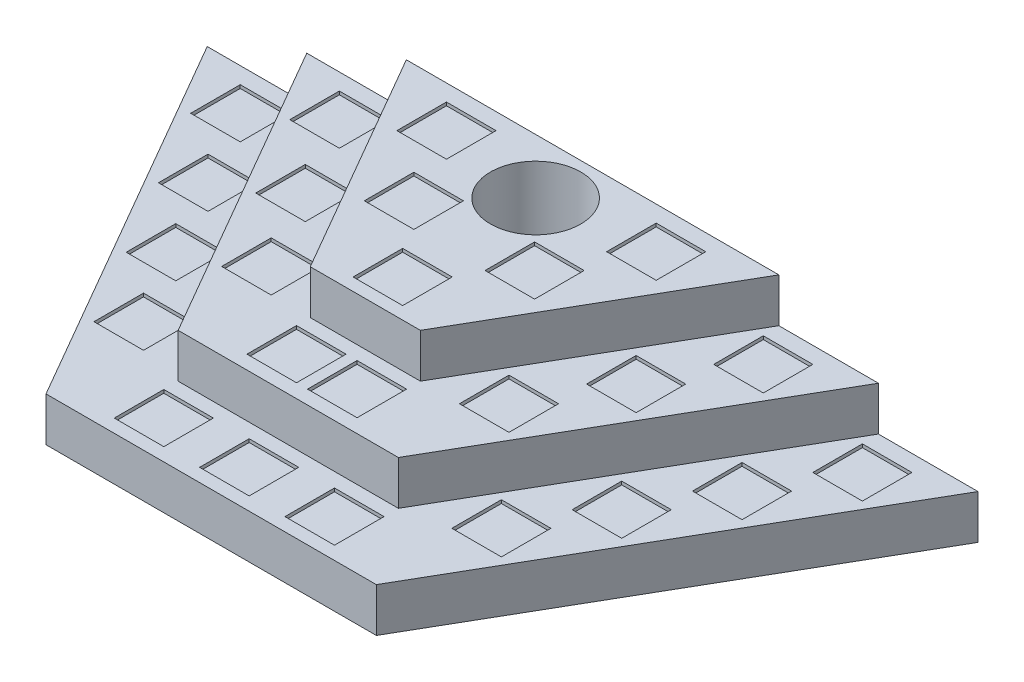
from build123d import *

# Parameters (mm, degrees)
BOSS_EXTRUDE1_DEPTH = 40
BOSS_EXTRUDE2_DEPTH = 40
BOSS_EXTRUDE3_DEPTH = 80
SKETCH7_W           = 45
SKETCH7_H           = 45
CUT_EXTRUDE2_DEPTH  = 3
SKETCH8_W           = 45
SKETCH8_H           = 45
CUT_EXTRUDE3_DEPTH  = 3
SKETCH9_W           = 45
SKETCH9_H           = 45
CUT_EXTRUDE4_DEPTH  = 3
SKETCH11_W          = 45
SKETCH11_H          = 45
CUT_EXTRUDE5_DEPTH  = 3
SKETCH13_R          = 41
CUT_EXTRUDE6_DEPTH  = 117


with BuildPart() as part:
    # Sketch1 → Boss-Extrude1 (new body)
    with BuildSketch(Plane(origin=(0, 0, 0), x_dir=(1, 0, 0), z_dir=(0, 1, 0))):
        Polygon((-150, 0), (150, 0), (350, 346.410161514), (-350, 346.410161514), align=None)
    extrude(amount=BOSS_EXTRUDE1_DEPTH)

    # Sketch3 → Boss-Extrude2 (add)
    with BuildSketch(Plane(origin=(0, 40, 0), x_dir=(1, 0, 0), z_dir=(0, 1, 0))):
        Polygon((-100, 70), (100, 70), (259.585481157, 346.410161514), (169.170962313, 346.410161514), (50, 140), (-50, 140), (-169.170962313, 346.410161514), (-259.585481157, 346.410161514), align=None)
    extrude(amount=BOSS_EXTRUDE2_DEPTH)

    # Sketch4 → Boss-Extrude3 (add)
    with BuildSketch(Plane(origin=(0, 40, 0), x_dir=(1, 0, 0), z_dir=(0, 1, 0))):
        Polygon((169.170962313, 346.410161514), (-169.170962313, 346.410161514), (-50, 140), (50, 140), align=None)
    extrude(amount=BOSS_EXTRUDE3_DEPTH)

    # Sketch7 → Cut-Extrude2 (cut)
    with BuildSketch(Plane(origin=(0, 40, 0), x_dir=(1, 0, 0), z_dir=(0, 1, 0))):
        with Locations((-282.5, 308.910161514)):
            Rectangle(SKETCH7_W, SKETCH7_H)
        with Locations((-77.5, 34.5)):
            Rectangle(SKETCH7_W, SKETCH7_H)
        with Locations((-242.5, 239.628129211)):
            Rectangle(SKETCH7_W, SKETCH7_H)
        with Locations((-202.5, 170.346096908)):
            Rectangle(SKETCH7_W, SKETCH7_H)
        with Locations((-162.5, 101.064064606)):
            Rectangle(SKETCH7_W, SKETCH7_H)
        with Locations((282.5, 308.910161514)):
            Rectangle(SKETCH7_W, SKETCH7_H)
        with Locations((162.5, 101.064064606)):
            Rectangle(SKETCH7_W, SKETCH7_H)
        with Locations((202.5, 170.346096908)):
            Rectangle(SKETCH7_W, SKETCH7_H)
        with Locations((242.5, 239.628129211)):
            Rectangle(SKETCH7_W, SKETCH7_H)
        with Locations((0, 34.5)):
            Rectangle(SKETCH7_W, SKETCH7_H)
        with Locations((77.5, 34.5)):
            Rectangle(SKETCH7_W, SKETCH7_H)
    extrude(amount=-CUT_EXTRUDE2_DEPTH, mode=Mode.SUBTRACT)

    # Sketch8 → Cut-Extrude3 (cut)
    with BuildSketch(Plane(origin=(0, 80, 0), x_dir=(1, 0, 0), z_dir=(0, 1, 0))):
        with Locations((-192.5, 308.910161514)):
            Rectangle(SKETCH8_W, SKETCH8_H)
        with Locations((-150.235026919, 235.705080757)):
            Rectangle(SKETCH8_W, SKETCH8_H)
        with Locations((-107.970053838, 162.5)):
            Rectangle(SKETCH8_W, SKETCH8_H)
        with Locations((192.5, 308.910161514)):
            Rectangle(SKETCH8_W, SKETCH8_H)
        with Locations((150.235026919, 235.705080757)):
            Rectangle(SKETCH8_W, SKETCH8_H)
        with Locations((107.970053838, 162.5)):
            Rectangle(SKETCH8_W, SKETCH8_H)
    extrude(amount=-CUT_EXTRUDE3_DEPTH, mode=Mode.SUBTRACT)

    # Sketch9 → Cut-Extrude4 (cut)
    with BuildSketch(Plane(origin=(0, 80, 0), x_dir=(1, 0, 0), z_dir=(0, 1, 0))):
        with Locations((-27.5, 105)):
            Rectangle(SKETCH9_W, SKETCH9_H)
        with Locations((27.5, 105)):
            Rectangle(SKETCH9_W, SKETCH9_H)
    extrude(amount=-CUT_EXTRUDE4_DEPTH, mode=Mode.SUBTRACT)

    # Sketch11 → Cut-Extrude5 (cut)
    with BuildSketch(Plane(origin=(0, 120, 0), x_dir=(1, 0, 0), z_dir=(0, 1, 0))):
        with Locations((-54.820508076, 238.910161514)):
            Rectangle(SKETCH11_W, SKETCH11_H)
        with Locations((-95.235026919, 308.910161514)):
            Rectangle(SKETCH11_W, SKETCH11_H)
        with Locations((54.820508076, 238.910161514)):
            Rectangle(SKETCH11_W, SKETCH11_H)
        with Locations((95.235026919, 308.910161514)):
            Rectangle(SKETCH11_W, SKETCH11_H)
        with Locations((0, 173.910161514)):
            Rectangle(SKETCH11_W, SKETCH11_H)
    extrude(amount=-CUT_EXTRUDE5_DEPTH, mode=Mode.SUBTRACT)

    # Sketch13 → Cut-Extrude6 (cut)
    with BuildSketch(Plane(origin=(0, 120, 0), x_dir=(1, 0, 0), z_dir=(0, 1, 0))):
        with Locations((-1.735026919, 296.410161514)):
            Circle(SKETCH13_R)
    extrude(amount=-CUT_EXTRUDE6_DEPTH, mode=Mode.SUBTRACT)


solid = part.part
